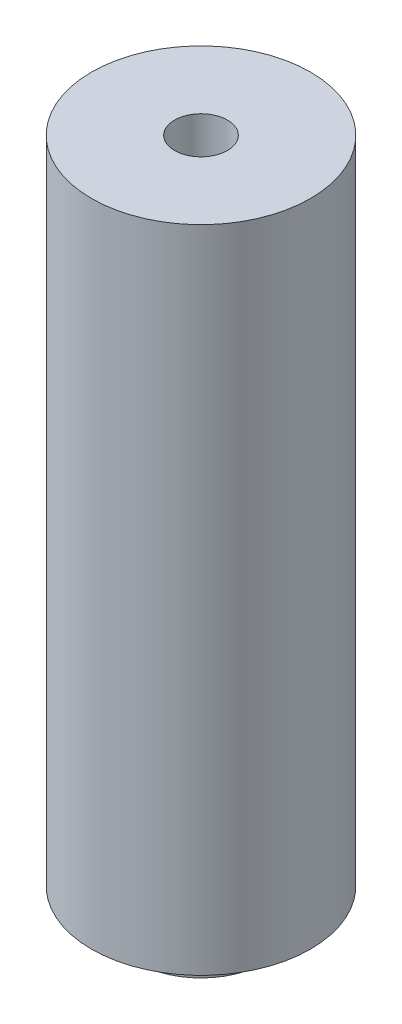
from build123d import *

# Parameters (mm, degrees)
SKETCH1_R           = 4
SKETCH1_R_2         = 0.965
BOSS_EXTRUDE1_DEPTH = 25
SKETCH2_R           = 4
SKETCH2_R_2         = 2.35
CUT_EXTRUDE1_DEPTH  = 1.25


with BuildPart() as part:
    # Sketch1 → Boss-Extrude1 (new body)
    with BuildSketch(Plane(origin=(0, 0, 0), x_dir=(1, 0, 0), z_dir=(0, 1, 0))):
        Circle(SKETCH1_R)
        Circle(SKETCH1_R_2, mode=Mode.SUBTRACT)
    extrude(amount=BOSS_EXTRUDE1_DEPTH)

    # Sketch2 → Cut-Extrude1 (cut)
    with BuildSketch(Plane.XZ):
        Circle(SKETCH2_R)
        Circle(SKETCH2_R_2, mode=Mode.SUBTRACT)
    extrude(amount=-CUT_EXTRUDE1_DEPTH, mode=Mode.SUBTRACT)


solid = part.part
